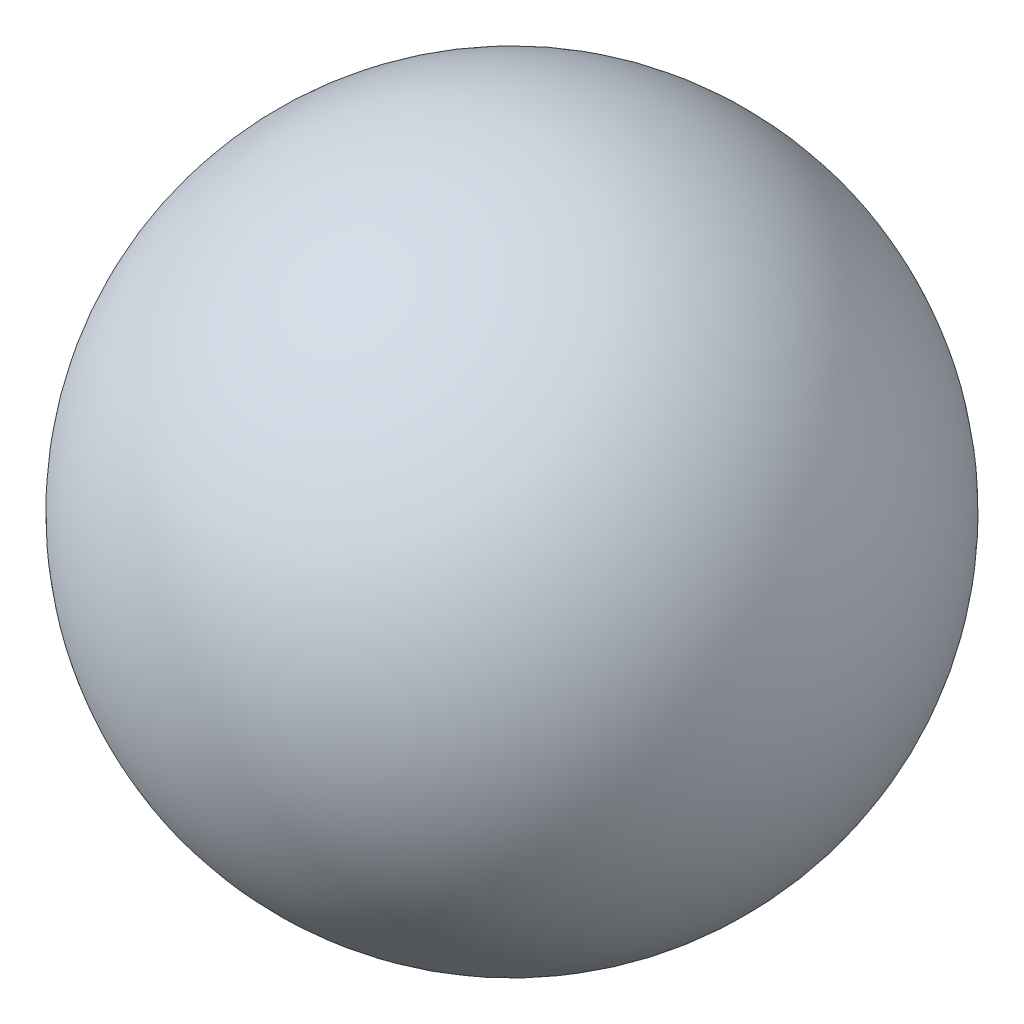
from build123d import *


with BuildPart() as part:
    # Sketch1 → Revolve1 (revolve)
    with BuildSketch(Plane(origin=(0, 0, 0), x_dir=(1, 0, 0), z_dir=(0, 1, 0))):
        with BuildLine():
            Line((0, 6.35), (0, -6.35))
            ThreePointArc((0, -6.35), (6.35, 0), (0, 6.35))
        make_face()
    revolve(axis=Axis((0, 0, -6.35), (0, 0, 1)))


solid = part.part
